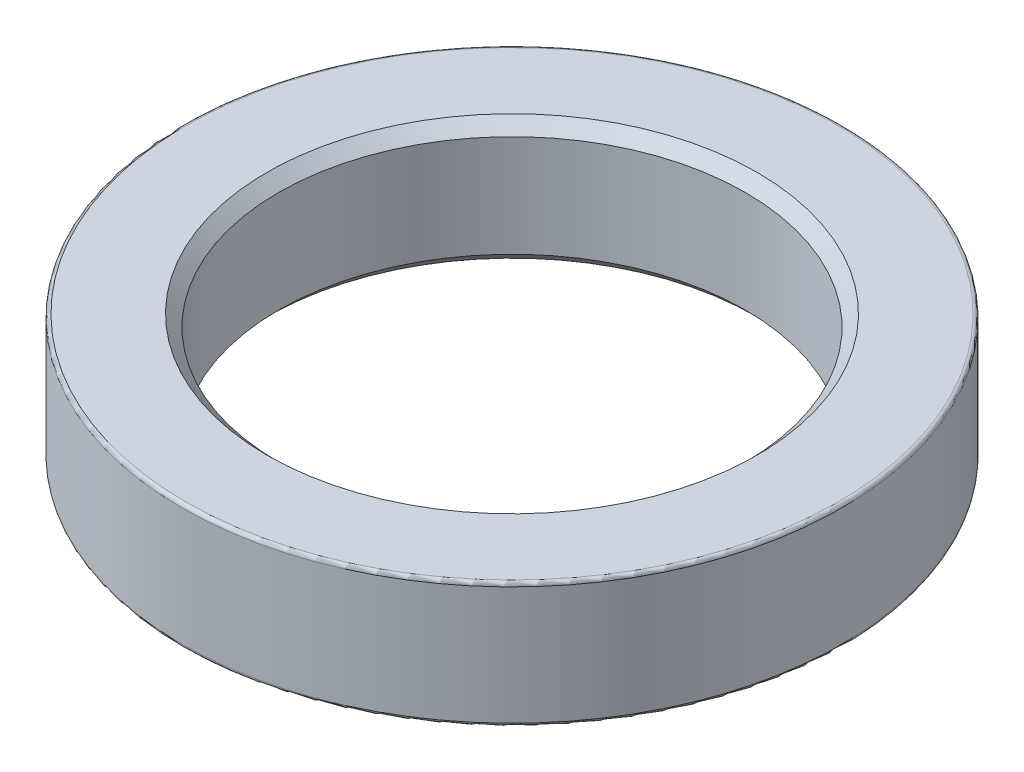
from build123d import *

# Parameters (mm, degrees)
SKETCH1_R           = 35.5981
BOSS_EXTRUDE1_DEPTH = 13.5128
SKETCH2_R           = 25.2095
CUT_EXTRUDE1_DEPTH  = 40.64
FILLET1_R           = 0.381
FILLET2_R           = 0.381
CHAMFER1_SIZE       = 1.2573
CHAMFER2_SIZE       = 1.2573


with BuildPart() as part:
    # Sketch1 → Boss-Extrude1 (new body)
    with BuildSketch(Plane(origin=(0, 0, 0), x_dir=(1, 0, 0), z_dir=(0, 1, 0))):
        Circle(SKETCH1_R)
    extrude(amount=BOSS_EXTRUDE1_DEPTH)

    # Sketch2 → Cut-Extrude1 (cut)
    with BuildSketch(Plane(origin=(0, 13.5128, 0), x_dir=(1, 0, 0), z_dir=(0, 1, 0))):
        Circle(SKETCH2_R)
    extrude(amount=-CUT_EXTRUDE1_DEPTH, mode=Mode.SUBTRACT)

    # Fillet1
    fillet1_edges = [part.edges().sort_by_distance(p)[0] for p in [
        (-35.5981, 13.5128, 0),
    ]]
    fillet(fillet1_edges, radius=FILLET1_R)

    # Fillet2
    fillet2_edges = [part.edges().sort_by_distance(p)[0] for p in [
        (-35.5981, 0, 0),
    ]]
    fillet(fillet2_edges, radius=FILLET2_R)

    # Chamfer1
    chamfer1_edges = [part.edges().sort_by_distance(p)[0] for p in [
        (-25.2095, 13.5128, 0),
    ]]
    chamfer(chamfer1_edges, length=CHAMFER1_SIZE)

    # Chamfer2
    chamfer2_edges = [part.edges().sort_by_distance(p)[0] for p in [
        (-25.2095, 0, 0),
    ]]
    chamfer(chamfer2_edges, length=CHAMFER2_SIZE)


solid = part.part
